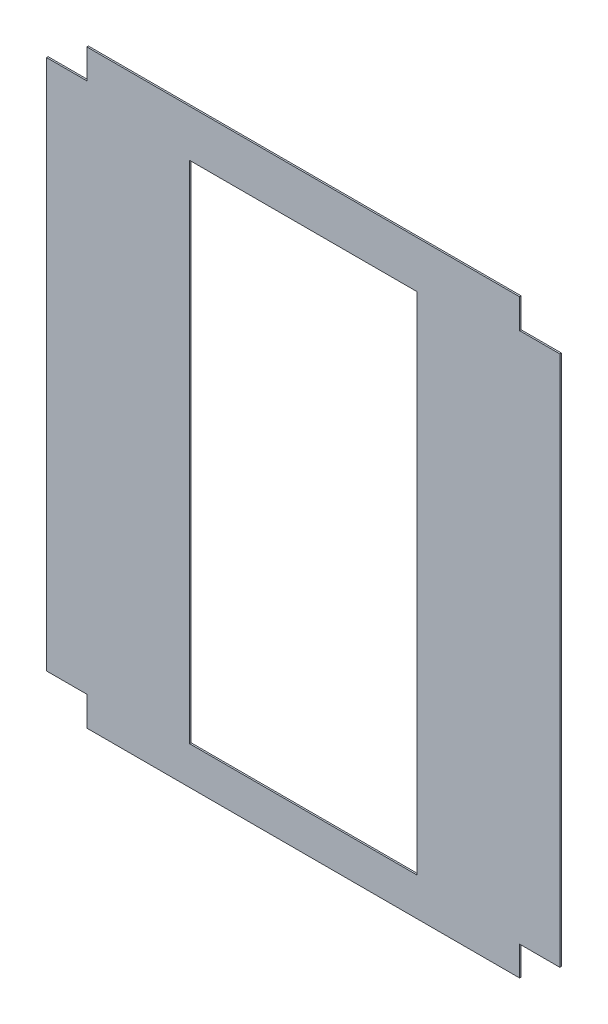
from build123d import *

# Parameters (mm, degrees)
SKETCH1_W           = 914.4
SKETCH1_H           = 2032
BOSS_EXTRUDE2_DEPTH = 6.35


with BuildPart() as part:
    # Sketch1 → Boss-Extrude2 (new body)
    with BuildSketch(Plane.XY):
        Polygon((686.529697289, 1180.785588374), (686.529697289, 1062.675588374), (848.581697289, 1062.675588374), (848.581697289, -1073.952151658), (686.529697289, -1073.952151658), (686.529697289, -1192.062151658), (477.952095391, -1192.062151658), (-436.447904609, -1192.062151658), (-1053.973, -1192.062151658), (-1053.973, -1073.952151658), (-1216.025, -1073.952151658), (-1216.025, 1062.675588374), (-1053.973, 1062.675588374), (-1053.973, 1180.785588374), align=None)
        with Locations((-183.515, -23.662151658)):
            Rectangle(SKETCH1_W, SKETCH1_H, mode=Mode.SUBTRACT)
    extrude(amount=BOSS_EXTRUDE2_DEPTH)


solid = part.part
